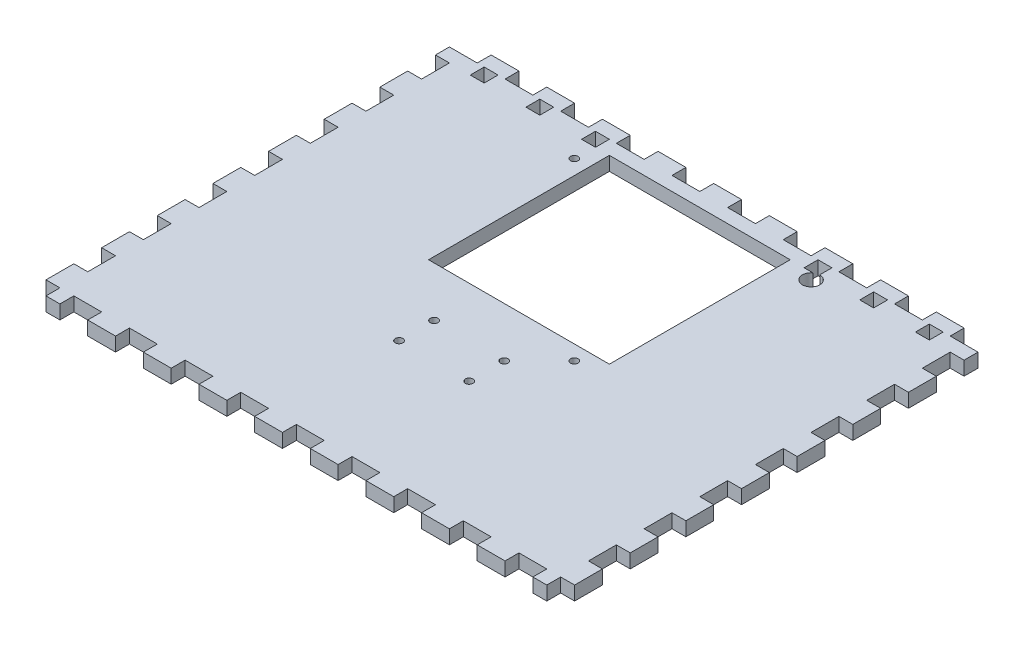
from build123d import *

# Parameters (mm, degrees)
SKETCH1_W            = 241.3
SKETCH1_H            = 254
BOSS_EXTRUDE1_DEPTH  = 6.35
SKETCH2_W            = 6.35
SKETCH2_H            = 12.7
CUT_EXTRUDE1_DEPTH   = 351.402643398
LPATTERN1_COUNT      = 10
LPATTERN1_PITCH      = 25.4
SKETCH3_W            = 12.7
SKETCH3_H            = 6.35
CUT_EXTRUDE2_DEPTH   = 351.402643398
LPATTERN2_COUNT      = 10
LPATTERN2_PITCH      = 25.4
SKETCH4_W            = 241.3
SKETCH4_H            = 57.15
CUT_EXTRUDE3_DEPTH   = 351.402643398
SKETCH5_W            = 12.7
SKETCH5_H            = 6.35
CUT_EXTRUDE4_DEPTH   = 351.402643398
LPATTERN3_COUNT      = 10
LPATTERN3_PITCH      = 25.4
SKETCH6_W            = 82.55
SKETCH6_H            = 82.55
CUT_EXTRUDE5_DEPTH   = 351.402643398
SKETCH7_W            = 6.35
SKETCH7_H            = 6.35
CUT_EXTRUDE6_DEPTH   = 351.402643398
LPATTERN4_COUNT      = 9
LPATTERN4_PITCH      = 25.4
SKETCH8_R            = 1.75
CUT_EXTRUDE7_DEPTH   = 351.402643398
LPATTERN5_COUNT      = 13
LPATTERN5_PITCH      = 16
LPATTERN5_COUNT_DIR2 = 11
LPATTERN5_PITCH_DIR2 = 16
SKETCH9_W            = 48.045746174
SKETCH9_H            = 167.078000208
SKETCH9_W_2          = 46.314367934
SKETCH9_W_3          = 108.643984591
SKETCH9_H_2          = 41.120233212
SKETCH9_W_4          = 31.284165216
SKETCH9_H_3          = 8.622263637
SKETCH9_W_5          = 25.970673607
SKETCH9_H_4          = 10.388269443
SKETCH9_W_6          = 15.149559605
SKETCH9_W_7          = 30.731963769
SKETCH9_W_8          = 73.583575221
SKETCH9_H_5          = 8.656891202
SKETCH9_W_9          = 14.283870484
SKETCH9_W_10         = 8.224046642
SKETCH9_H_6          = 72.285041541
SKETCH9_W_11         = 11.748458615
SKETCH9_H_7          = 59.732549298
SKETCH9_W_12         = 9.178793531
SKETCH9_W_13         = 27.063281488
BOSS_EXTRUDE2_DEPTH  = 6.35
SKETCH10_R           = 3.96875
CUT_EXTRUDE8_DEPTH   = 351.402643398


with BuildPart() as part:
    # Sketch1 → Boss-Extrude1 (new body)
    with BuildSketch(Plane(origin=(0, 0, 0), x_dir=(1, 0, 0), z_dir=(0, 1, 0))):
        with Locations((120.65, 127)):
            Rectangle(SKETCH1_W, SKETCH1_H)
    extrude(amount=BOSS_EXTRUDE1_DEPTH)

    # Sketch2 → Cut-Extrude1 (cut, through all)
    with BuildSketch(Plane(origin=(0, 6.35, 0), x_dir=(1, 0, 0), z_dir=(0, 1, 0))):
        with Locations((3.175, 6.35)):
            Rectangle(SKETCH2_W, SKETCH2_H)
        with Locations((238.125, 6.35)):
            Rectangle(SKETCH2_W, SKETCH2_H)
    cut_extrude1 = extrude(amount=-CUT_EXTRUDE1_DEPTH, mode=Mode.SUBTRACT)

    # LPattern1: Cut-Extrude1 ×10
    with Locations(*[(0, 0, -i * LPATTERN1_PITCH) for i in range(1, LPATTERN1_COUNT)]):
        add(cut_extrude1, mode=Mode.SUBTRACT)

    # Sketch3 → Cut-Extrude2 (cut, through all)
    with BuildSketch(Plane(origin=(0, 6.35, 0), x_dir=(1, 0, 0), z_dir=(0, 1, 0))):
        with Locations((6.35, 3.175)):
            Rectangle(SKETCH3_W, SKETCH3_H)
        with Locations((6.35, 250.825)):
            Rectangle(SKETCH3_W, SKETCH3_H)
    cut_extrude2 = extrude(amount=-CUT_EXTRUDE2_DEPTH, mode=Mode.SUBTRACT)

    # LPattern2: Cut-Extrude2 ×10
    with Locations(*[(i * LPATTERN2_PITCH, 0, 0) for i in range(1, LPATTERN2_COUNT)]):
        add(cut_extrude2, mode=Mode.SUBTRACT)

    # Sketch4 → Cut-Extrude3 (cut, through all)
    with BuildSketch(Plane(origin=(0, 6.35, 0), x_dir=(1, 0, 0), z_dir=(0, 1, 0))):
        with Locations((120.65, 28.575)):
            Rectangle(SKETCH4_W, SKETCH4_H)
    extrude(amount=-CUT_EXTRUDE3_DEPTH, mode=Mode.SUBTRACT)

    # Sketch5 → Cut-Extrude4 (cut, through all)
    with BuildSketch(Plane(origin=(0, 6.35, 0), x_dir=(1, 0, 0), z_dir=(0, 1, 0))):
        with Locations((19.05, 60.325)):
            Rectangle(SKETCH5_W, SKETCH5_H)
    cut_extrude4 = extrude(amount=-CUT_EXTRUDE4_DEPTH, mode=Mode.SUBTRACT)

    # LPattern3: Cut-Extrude4 ×10
    with Locations(*[(i * LPATTERN3_PITCH, 0, 0) for i in range(1, LPATTERN3_COUNT)]):
        add(cut_extrude4, mode=Mode.SUBTRACT)

    # Sketch6 → Cut-Extrude5 (cut, through all)
    with BuildSketch(Plane(origin=(0, 6.35, 0), x_dir=(1, 0, 0), z_dir=(0, 1, 0))):
        with Locations((120.65, 200.025)):
            Rectangle(SKETCH6_W, SKETCH6_H)
    extrude(amount=-CUT_EXTRUDE5_DEPTH, mode=Mode.SUBTRACT)

    # Sketch7 → Cut-Extrude6 (cut, through all)
    with BuildSketch(Plane(origin=(0, 6.35, 0), x_dir=(1, 0, 0), z_dir=(0, 1, 0))):
        with Locations((19.05, 244.475)):
            Rectangle(SKETCH7_W, SKETCH7_H)
    cut_extrude6 = extrude(amount=-CUT_EXTRUDE6_DEPTH, mode=Mode.SUBTRACT)

    # LPattern4: Cut-Extrude6 ×9, 3 skipped
    with Locations(*[(i * LPATTERN4_PITCH, 0, 0) for i in range(1, LPATTERN4_COUNT) if i not in (3, 4, 5)]):
        add(cut_extrude6, mode=Mode.SUBTRACT)

    # Sketch8 → Cut-Extrude7 (cut, through all)
    with BuildSketch(Plane(origin=(0, 6.35, 0), x_dir=(1, 0, 0), z_dir=(0, 1, 0))):
        with Locations(Location((24.65, 72.025, 0), (0, 0, 270))):
            Circle(SKETCH8_R)
    cut_extrude7 = extrude(amount=-CUT_EXTRUDE7_DEPTH, mode=Mode.SUBTRACT)

    # LPattern5: Cut-Extrude7 13 × 11
    with Locations(*[(i * LPATTERN5_PITCH, 0, -j * LPATTERN5_PITCH_DIR2) for i in range(LPATTERN5_COUNT) for j in range(LPATTERN5_COUNT_DIR2) if (i, j) != (0, 0)]):
        add(cut_extrude7, mode=Mode.SUBTRACT)

    # Sketch9 → Boss-Extrude2 (add, through all)
    with BuildSketch(Plane(origin=(0, 6.35, 0), x_dir=(1, 0, 0), z_dir=(0, 1, 0))):
        with Locations((38.409533576, 152.545088079)):
            Rectangle(SKETCH9_W, SKETCH9_H)
        with Locations((203.756155544, 152.545088079)):
            Rectangle(SKETCH9_W_2, SKETCH9_H)
        with Locations((121.948533681, 89.566204581)):
            Rectangle(SKETCH9_W_3, SKETCH9_H_2)
        with Locations((83.268623993, 135.798764893)):
            Rectangle(SKETCH9_W_4, SKETCH9_H_3)
        with Locations((80.611878189, 120.51459063)):
            Rectangle(SKETCH9_W_5, SKETCH9_H_4)
        with Locations((122.814222801, 120.51459063)):
            Rectangle(SKETCH9_W_6, SKETCH9_H_4)
        with Locations((160.904544092, 120.51459063)):
            Rectangle(SKETCH9_W_7, SKETCH9_H_4)
        with Locations((104.418328996, 151.679398959)):
            Rectangle(SKETCH9_W_8, SKETCH9_H_5)
        with Locations((169.128590734, 151.679398959)):
            Rectangle(SKETCH9_W_9, SKETCH9_H_5)
        with Locations((169.128590734, 199.941567413)):
            Rectangle(SKETCH9_W_10, SKETCH9_H_6)
        with Locations((73.500770692, 193.665321291)):
            Rectangle(SKETCH9_W_11, SKETCH9_H_7)
        with Locations((119.828839764, 135.798764893)):
            Rectangle(SKETCH9_W_12, SKETCH9_H_3)
        with Locations((162.738885232, 135.798764893)):
            Rectangle(SKETCH9_W_13, SKETCH9_H_3)
    extrude(amount=-BOSS_EXTRUDE2_DEPTH)

    # Sketch10 → Cut-Extrude8 (cut, through all)
    with BuildSketch(Plane(origin=(0, 6.35, 0), x_dir=(1, 0, 0), z_dir=(0, 1, 0))):
        with Locations((174.625, 238.125)):
            Circle(SKETCH10_R)
    extrude(amount=-CUT_EXTRUDE8_DEPTH, mode=Mode.SUBTRACT)


solid = part.part
